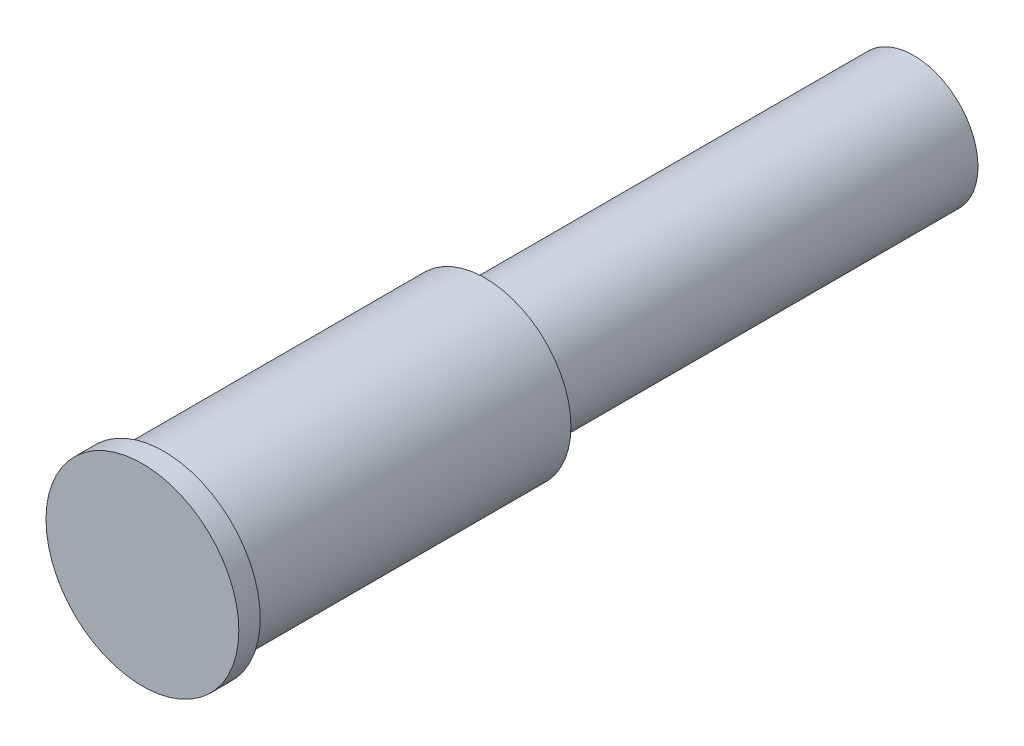
from build123d import *

# Parameters (mm, degrees)
SKETCH_1_R      = 3
EXTRUDE_1_DEPTH = 20
SKETCH_2_R      = 4
EXTRUDE_2_DEPTH = 15
SKETCH_3_R      = 4.5
EXTRUDE_3_DEPTH = 1


with BuildPart() as part:
    # 草图1 → 凸台-拉伸1 (new body)
    with BuildSketch(Plane.XY):
        Circle(SKETCH_1_R)
    extrude(amount=EXTRUDE_1_DEPTH)

    # 草图2 → 凸台-拉伸2 (add)
    with BuildSketch(Plane.XY.offset(20)):
        Circle(SKETCH_2_R)
    extrude(amount=EXTRUDE_2_DEPTH)

    # 草图3 → 凸台-拉伸3 (add)
    with BuildSketch(Plane.XY.offset(35)):
        Circle(SKETCH_3_R)
    extrude(amount=EXTRUDE_3_DEPTH)


solid = part.part
